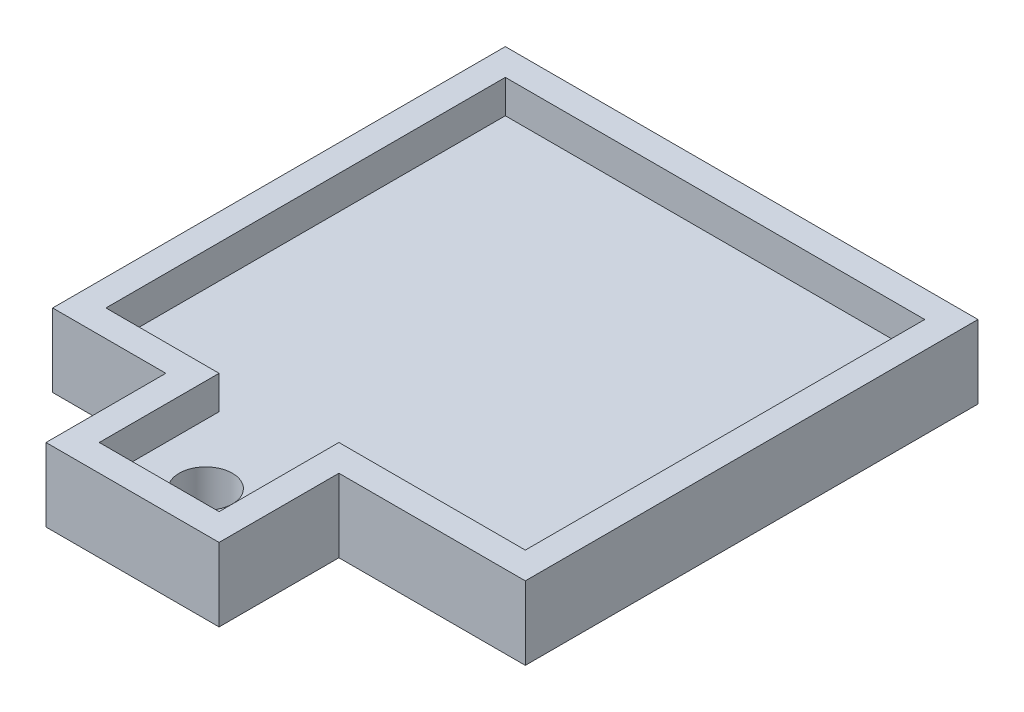
from build123d import *

# Parameters (mm, degrees)
SKETCH1_R           = 20
BOSS_EXTRUDE1_DEPTH = 30
SCALE1_SCALE        = 0.1
BOSS_EXTRUDE2_DEPTH = 5.5


with BuildPart() as part:
    # Sketch1 → Boss-Extrude1 (new body)
    with BuildSketch(Plane(origin=(0, 0, 0), x_dir=(1, 0, 0), z_dir=(0, 1, 0))):
        Polygon((17.5, -90), (17.5, 0), (157.5, 0), (157.5, 300), (-157.5, 300), (-157.5, 0), (-72.5, 0), (-72.5, -90), align=None)
        with Locations((-27.5, -55)):
            Circle(SKETCH1_R, mode=Mode.SUBTRACT)
    extrude(amount=BOSS_EXTRUDE1_DEPTH)


with BuildPart() as part_1:
    # Scale1: scaled about (-1.856978843, 15, -136.956329807)
    add(part.part.scale(SCALE1_SCALE).moved(Location((-1.671280959, 13.5, -123.260696826))))

    # Sketch2 → Boss-Extrude2 (add)
    with BuildSketch(Plane.XZ.offset(-13.5)):
        Polygon((-19.421280958, -155.260696826), (-19.421280958, -121.260696826), (-10.921280958, -121.260696826), (-10.921280958, -112.260696826), (2.078719042, -112.260696826), (2.078719042, -121.260696826), (16.078719042, -121.260696826), (16.078719042, -155.260696826), align=None)
        Polygon((14.078719042, -153.260696826), (14.078719042, -123.260696826), (0.078719042, -123.260696826), (0.078719042, -114.260696826), (-8.921280958, -114.260696826), (-8.921280958, -123.260696826), (-17.421280958, -123.260696826), (-17.421280958, -153.260696826), align=None, mode=Mode.SUBTRACT)
    extrude(amount=-BOSS_EXTRUDE2_DEPTH)


solid = part_1.part
